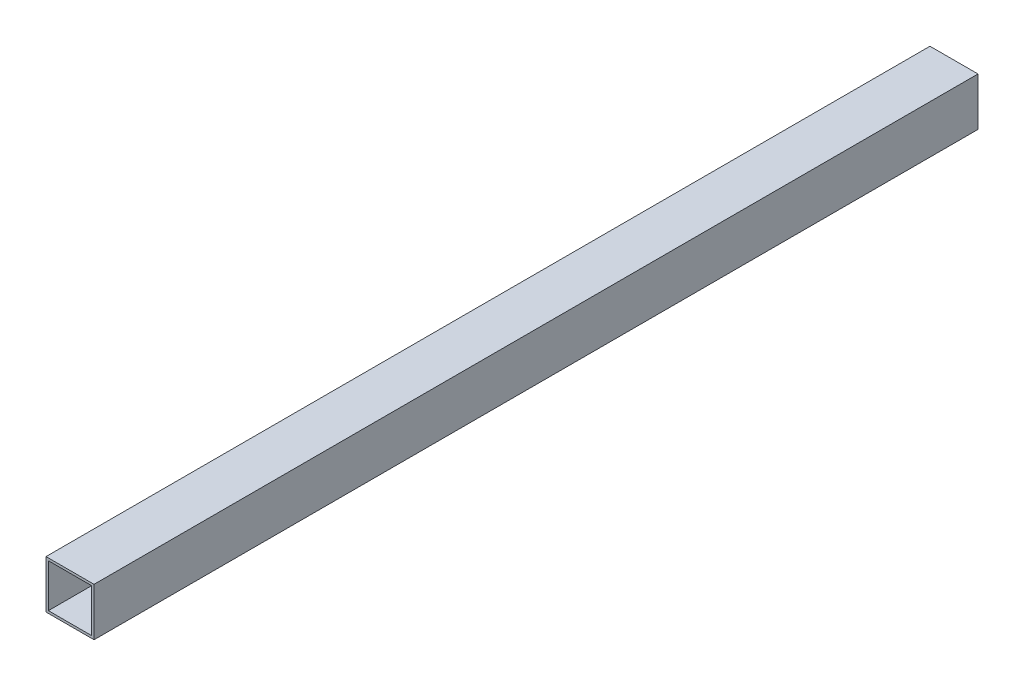
from build123d import *

# Parameters (mm, degrees)
SKETCH1_W           = 100
SKETCH1_H           = 100
SKETCH1_W_2         = 90
SKETCH1_H_2         = 90
BOSS_EXTRUDE1_DEPTH = 920


with BuildPart() as part:
    # Sketch1 → Boss-Extrude1 (new body, symmetric)
    with BuildSketch(Plane.XY):
        Rectangle(SKETCH1_W, SKETCH1_H)
        Rectangle(SKETCH1_W_2, SKETCH1_H_2, mode=Mode.SUBTRACT)
    extrude(amount=BOSS_EXTRUDE1_DEPTH, both=True)


solid = part.part
